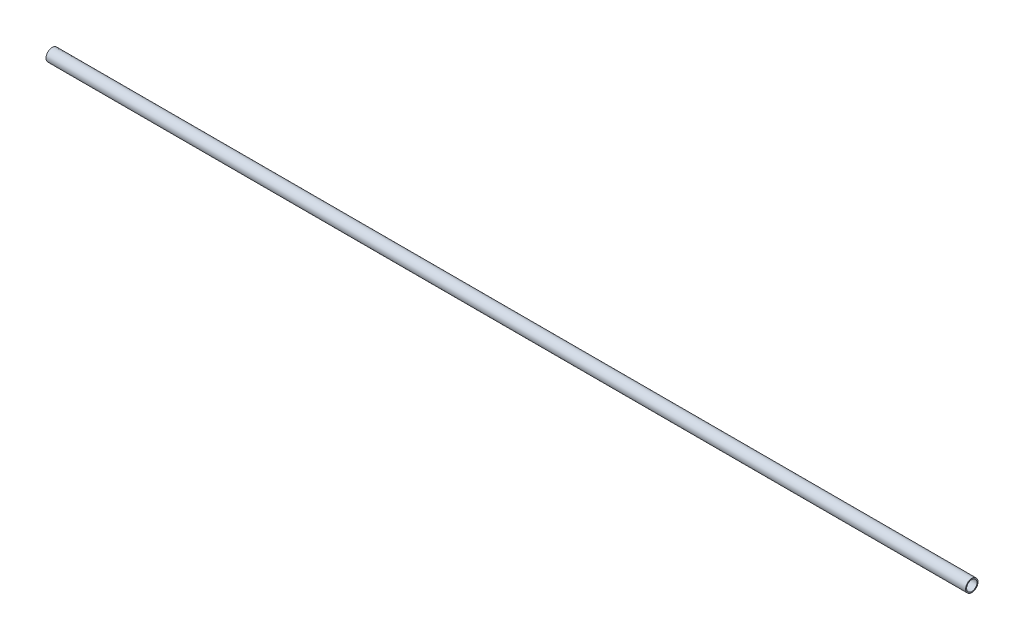
from build123d import *

# Parameters (mm, degrees)
SKETCH1_R           = 3.175
SKETCH1_R_2         = 2.667
BOSS_EXTRUDE1_DEPTH = 472.313


with BuildPart() as part:
    # Sketch1 → Boss-Extrude1 (new body)
    with BuildSketch(Plane(origin=(0, 0, 0), x_dir=(0, 0, -1), z_dir=(1, 0, 0))):
        Circle(SKETCH1_R)
        Circle(SKETCH1_R_2, mode=Mode.SUBTRACT)
    extrude(amount=-BOSS_EXTRUDE1_DEPTH)


solid = part.part
